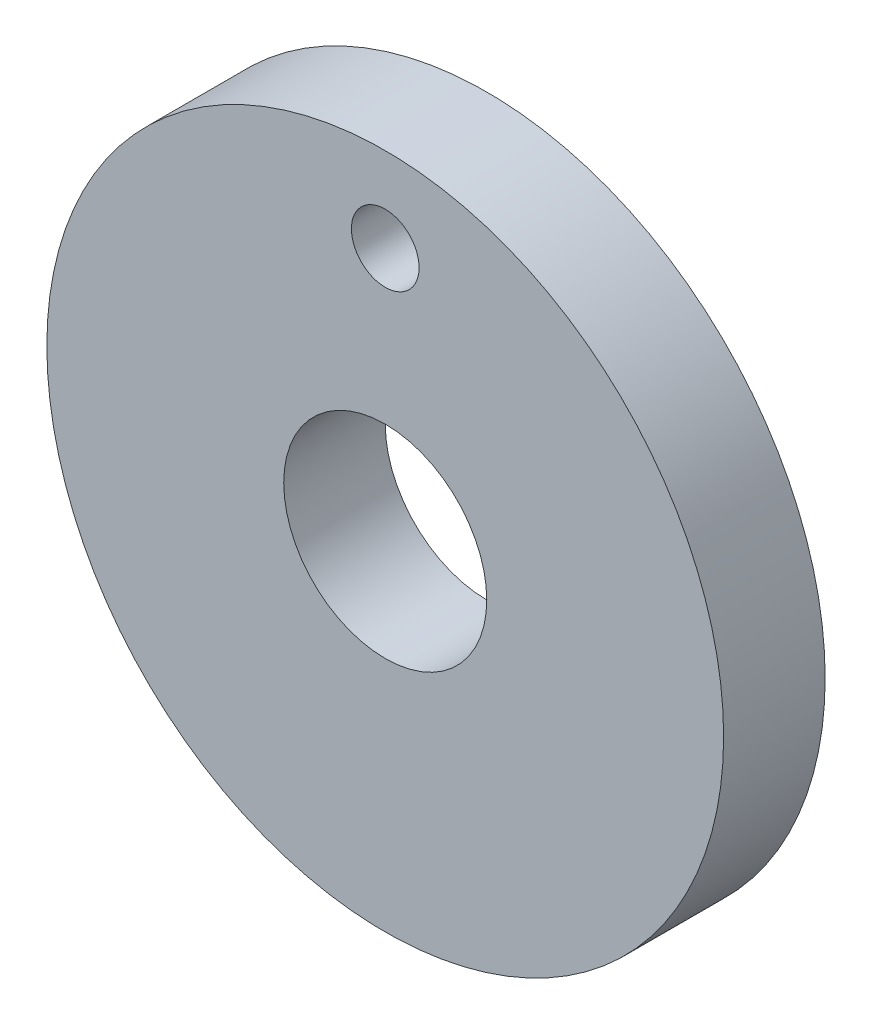
from build123d import *

# Parameters (mm, degrees)
ESQUISSE1_R        = 10
ESQUISSE1_R_2      = 1
ESQUISSE1_R_3      = 3
BOSS_EXTRU_1_DEPTH = 3


with BuildPart() as part:
    # Esquisse1 → Boss.-Extru.1 (new body)
    with BuildSketch(Plane.XY):
        Circle(ESQUISSE1_R)
        with Locations((0, 7.5)):
            Circle(ESQUISSE1_R_2, mode=Mode.SUBTRACT)
        Circle(ESQUISSE1_R_3, mode=Mode.SUBTRACT)
    extrude(amount=BOSS_EXTRU_1_DEPTH)


solid = part.part
